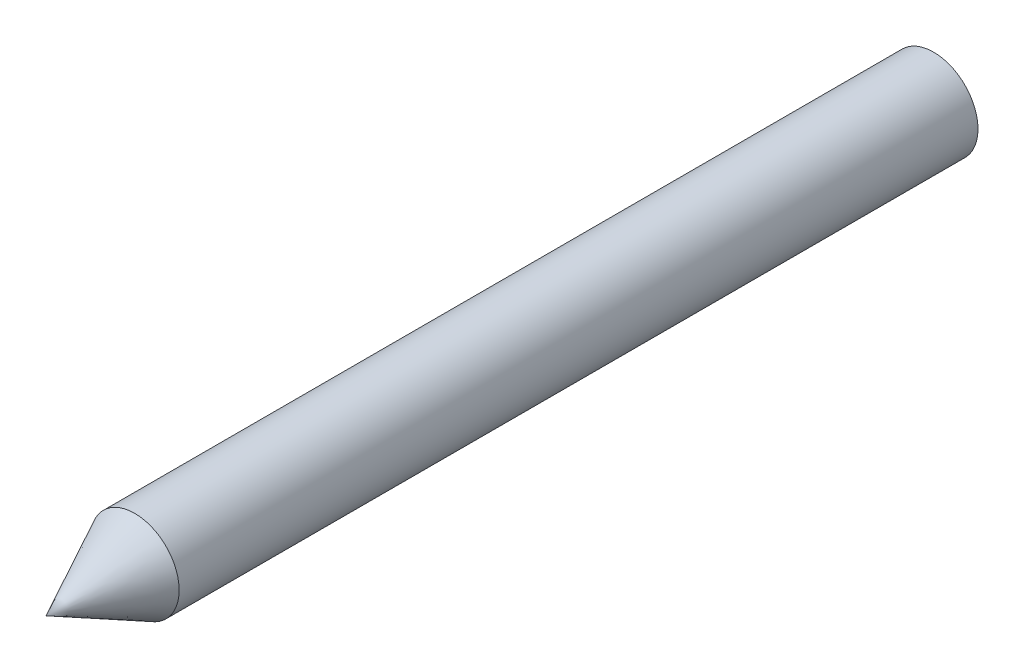
from build123d import *

# Parameters (mm, degrees)
SKETCH1_R           = 25
BOSS_EXTRUDE1_DEPTH = 450


with BuildPart() as part:
    # Sketch1 → Boss-Extrude1 (new body)
    with BuildSketch(Plane.XY):
        Circle(SKETCH1_R)
    extrude(amount=BOSS_EXTRUDE1_DEPTH)

    # Sketch2 → Revolve1 (revolve)
    with BuildSketch(Plane(origin=(0, 0, 0), x_dir=(1, 0, 0), z_dir=(0, 1, 0))):
        Polygon((0, -450), (-25, -450), (0, -500), align=None)
    revolve(axis=Axis((0, 0, 450), (0, 0, 1)))


solid = part.part
